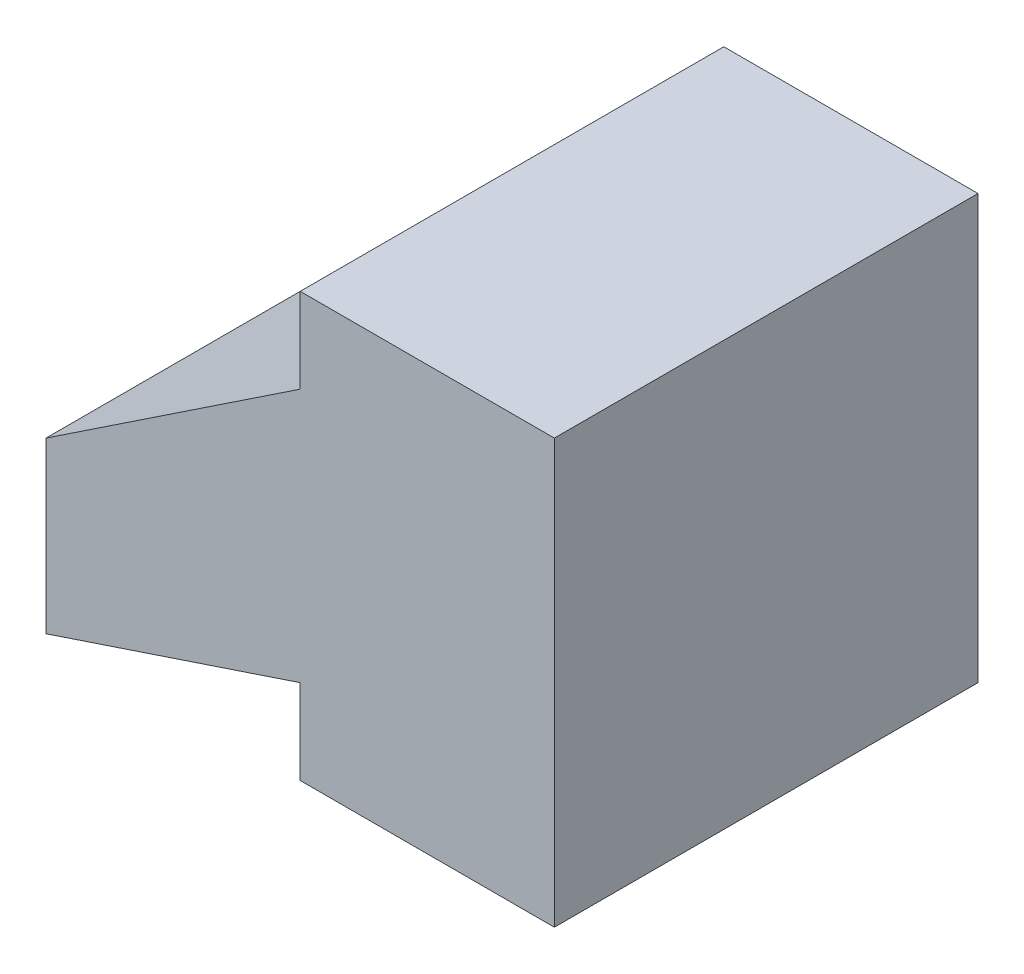
from build123d import *

# Parameters (mm, degrees)
BOSS_EXTRUDE1_DEPTH = 5


with BuildPart() as part:
    # Sketch1 → Boss-Extrude1 (new body)
    with BuildSketch(Plane.XY):
        Polygon((0, 0), (0, 1), (-3, 0), (-3, 2), (0, 4), (0, 5), (3, 5), (3, 0), align=None)
    extrude(amount=BOSS_EXTRUDE1_DEPTH)


solid = part.part
